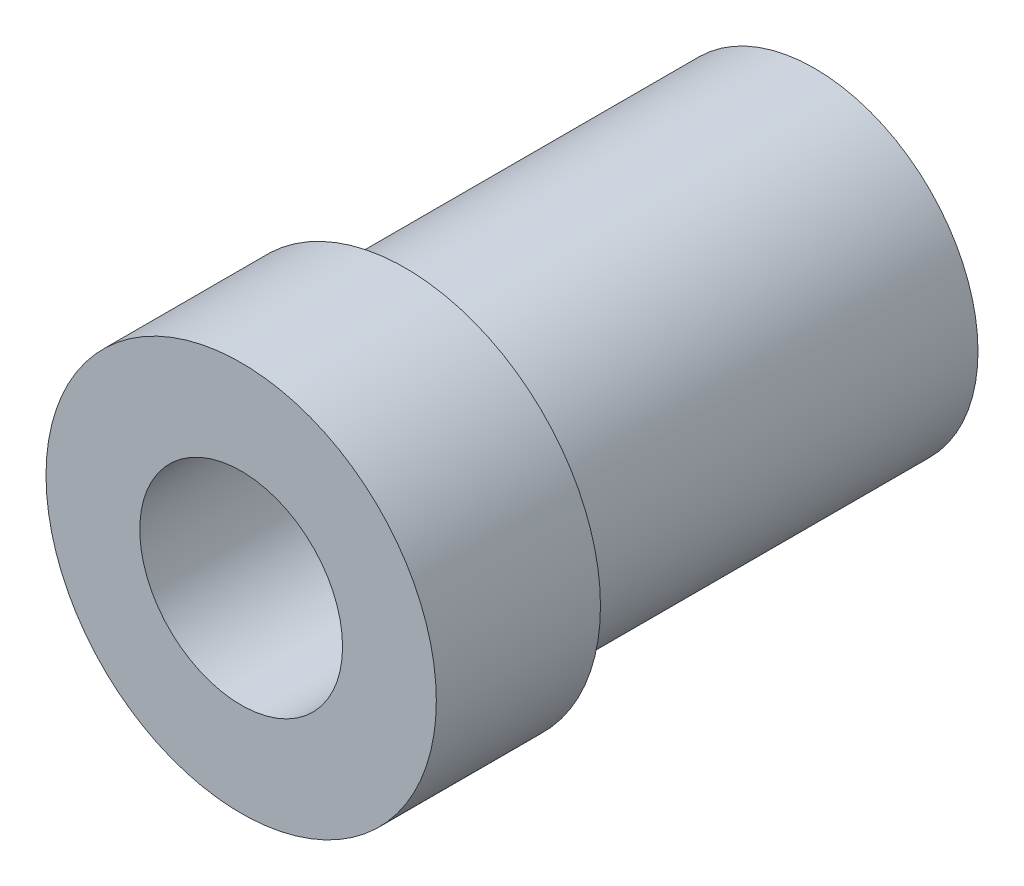
from build123d import *


with BuildPart() as part:
    # Sketch1 → Revolve1 (revolve)
    with BuildSketch(Plane(origin=(0, 0, 0), x_dir=(0, 0, -1), z_dir=(1, 0, 0))):
        Polygon((10.025594326, 2.481451816), (10.025594326, 3.999701303), (0.010080588, 3.999701303), (0.010080588, 4.776017407), (-4.007020747, 4.776017407), (-4.007020747, 2.481451816), align=None)
    revolve(axis=Axis((0, 0, 0), (0, 0, -1)))


solid = part.part
